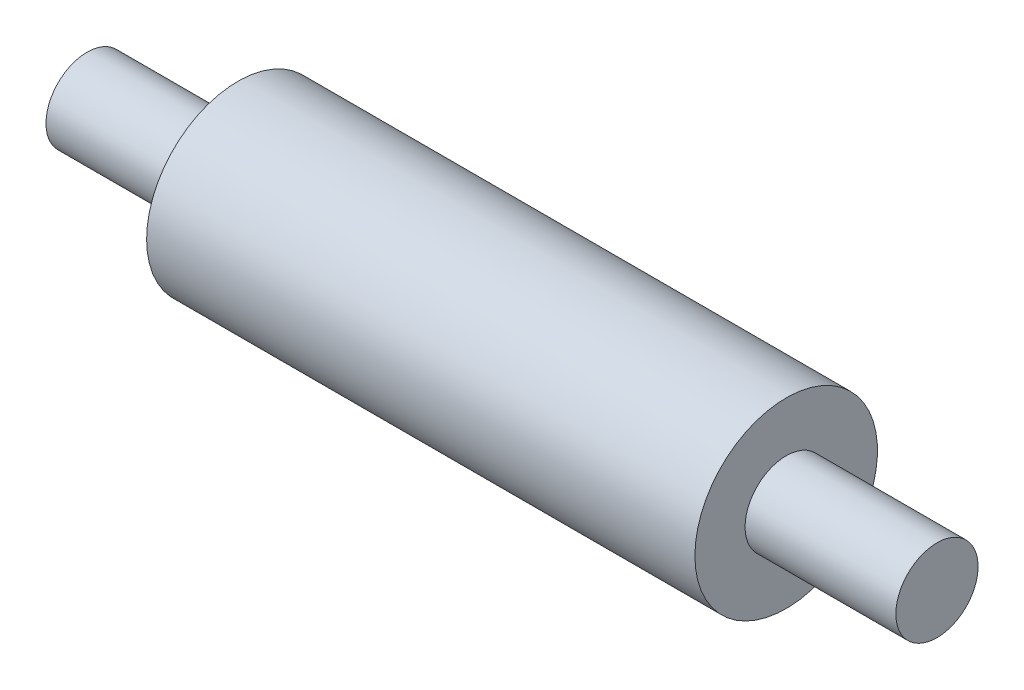
from build123d import *

# Parameters (mm, degrees)
SKETCH1_W = 5.5
SKETCH1_H = 1.5


with BuildPart() as part:
    # Sketch1 → Revolve1 (revolve)
    with BuildSketch(Plane.XY):
        Polygon((-10, 0), (10, 0), (10, 1.5), (10, 3.33), (-10, 3.33), (-10, 1.5), align=None)
        with Locations((-12.75, 0.75)):
            Rectangle(SKETCH1_W, SKETCH1_H)
        with Locations((12.75, 0.75)):
            Rectangle(SKETCH1_W, SKETCH1_H)
    revolve(axis=Axis((-15.5, 0, 0), (1, 0, 0)))


solid = part.part
